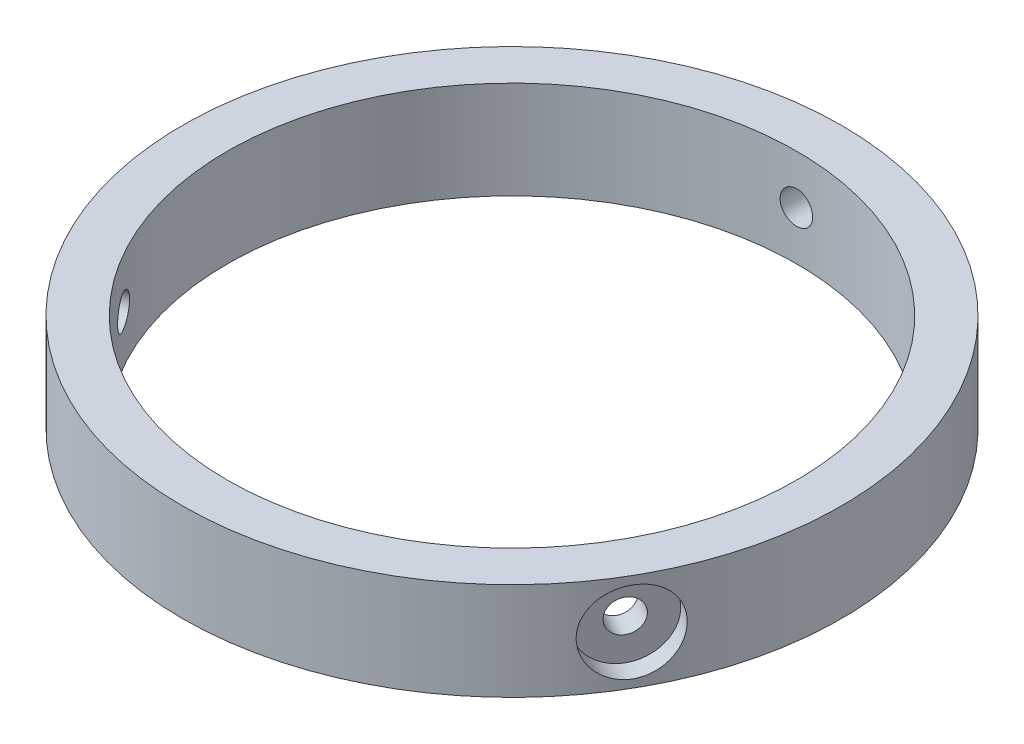
from build123d import *

# Parameters (mm, degrees)
BOSS_EXTRUDE1_DEPTH      = 8
BOSS_EXTRUDE1_DEPTH_BACK = 25
SKETCH1_R                = 17.45
SKETCH1_R_2              = 12.45
SKETCH2_R                = 20.25
SKETCH2_R_2              = 12.45
BOSS_EXTRUDE2_DEPTH      = 40
CUT_EXTRUDE1_START       = -221
SKETCH3_R                = 17.5
SKETCH3_R_2              = 12.45
CUT_EXTRUDE1_DEPTH       = 221
CUT_EXTRUDE2_DEPTH       = 221
CUT_EXTRUDE2_DEPTH_BACK  = 221
SKETCH4_W                = 78.3000253
SKETCH4_H                = 101.772836534
SKETCH5_R                = 1
CUT_EXTRUDE3_DEPTH       = 221
CUT_EXTRUDE4_START       = -19
SKETCH6_R                = 2.5
CUT_EXTRUDE4_DEPTH       = 221
CIRPATTERN1_COUNT        = 3


with BuildPart() as part:
    # Sketch1 → Boss-Extrude1 (new, two sides: drawn at the far end of the back side and taken through both)
    with BuildSketch(Plane(origin=(0, 0, 0), x_dir=(1, 0, 0), z_dir=(0, 1, 0)).offset(-BOSS_EXTRUDE1_DEPTH_BACK)):
        Circle(SKETCH1_R)
        Circle(SKETCH1_R_2, mode=Mode.SUBTRACT)
    extrude(amount=BOSS_EXTRUDE1_DEPTH + BOSS_EXTRUDE1_DEPTH_BACK)

    # Sketch2 → Boss-Extrude2 (add)
    with BuildSketch(Plane(origin=(0, 8, 0), x_dir=(1, 0, 0), z_dir=(0, 1, 0))):
        Circle(SKETCH2_R)
        Circle(SKETCH2_R_2, mode=Mode.SUBTRACT)
    extrude(amount=BOSS_EXTRUDE2_DEPTH)

    # Sketch3 → Cut-Extrude1 (cut)
    with BuildSketch(Plane(origin=(0, 48, 0), x_dir=(1, 0, 0), z_dir=(0, 1, 0)).offset(CUT_EXTRUDE1_START)):
        Circle(SKETCH3_R)
        Circle(SKETCH3_R_2, mode=Mode.SUBTRACT)
    extrude(amount=CUT_EXTRUDE1_DEPTH, mode=Mode.SUBTRACT)

    # Sketch4 → Cut-Extrude2 (cut, two sides: drawn at the far end of the back side and taken through both)
    with BuildSketch(Plane(origin=(0, 0, 0), x_dir=(0, 0, -1), z_dir=(1, 0, 0)).offset(-CUT_EXTRUDE2_DEPTH_BACK)):
        with Locations((-0.109307072, 64.886418267)):
            Rectangle(SKETCH4_W, SKETCH4_H)
    extrude(amount=CUT_EXTRUDE2_DEPTH + CUT_EXTRUDE2_DEPTH_BACK, mode=Mode.SUBTRACT)

    # Sketch5 → Cut-Extrude3 (cut)
    with BuildSketch(Plane.XY):
        with Locations((0, 11)):
            Circle(SKETCH5_R)
    cut_extrude3 = extrude(amount=-CUT_EXTRUDE3_DEPTH, mode=Mode.SUBTRACT)

    # Sketch6 → Cut-Extrude4 (cut)
    with BuildSketch(Plane.XY.offset(CUT_EXTRUDE4_START)):
        with Locations((0, 11)):
            Circle(SKETCH6_R)
    cut_extrude4 = extrude(amount=-CUT_EXTRUDE4_DEPTH, mode=Mode.SUBTRACT)

    # CirPattern1: Cut-Extrude3, Cut-Extrude4 ×3 about axis
    cirpattern1_axis = Axis((0, 14, 0), (0, -1, 0))
    add([cut_extrude3.rotate(cirpattern1_axis, i * 360 / CIRPATTERN1_COUNT) for i in range(1, CIRPATTERN1_COUNT)], mode=Mode.SUBTRACT)
    add([cut_extrude4.rotate(cirpattern1_axis, i * 360 / CIRPATTERN1_COUNT) for i in range(1, CIRPATTERN1_COUNT)], mode=Mode.SUBTRACT)


solid = part.part
